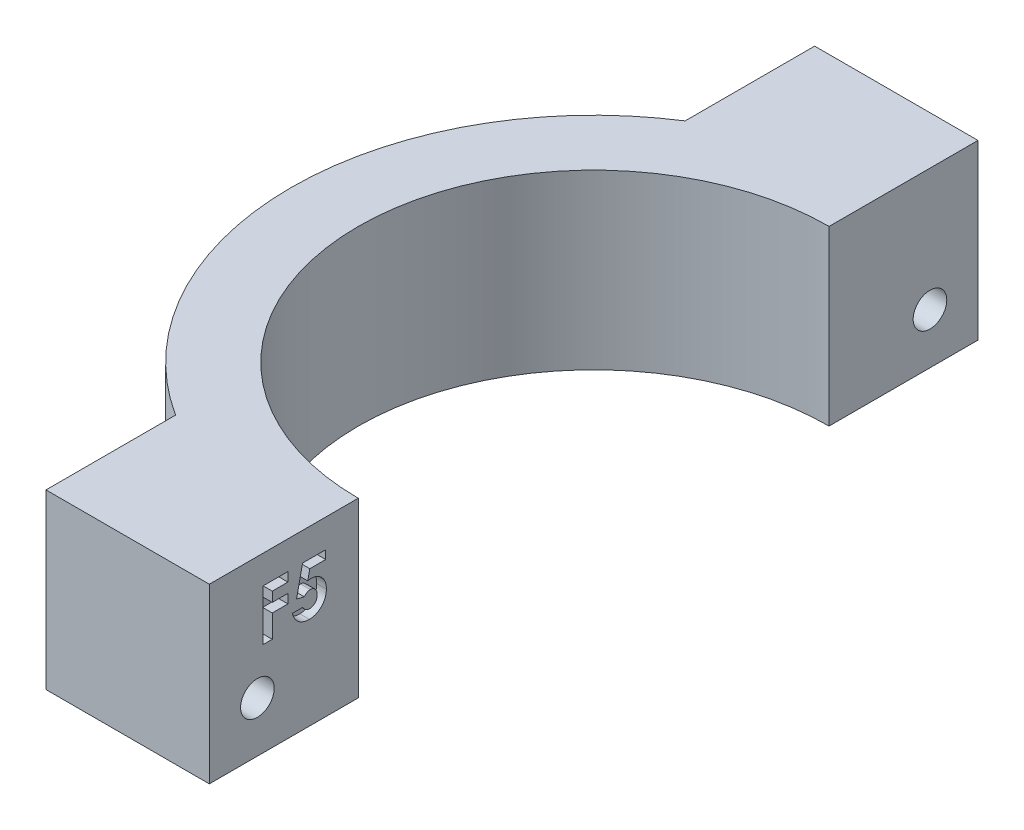
from build123d import *

# Parameters (mm, degrees)
BOSS_EXTRUDE1_DEPTH = 18
SKETCH2_R           = 1.75
CUT_EXTRUDE1_DEPTH  = 32.5
CUT_EXTRUDE2_DEPTH  = 1
CUT_EXTRUDE3_DEPTH  = 5


with BuildPart() as part:
    # Sketch1 → Boss-Extrude1 (new body)
    with BuildSketch(Plane(origin=(0, 0, 0), x_dir=(1, 0, 0), z_dir=(0, 1, 0))):
        with BuildLine():
            Line((-12.998275301, 32.528571429), (-29.998275301, 32.528571429))
            Line((-29.998275301, 32.528571429), (-29.998275301, 19.047432641))
            ThreePointArc((-29.998275301, 19.047432641), (-21.855641496, 22.757647896), (-12.998275301, 24.028571429))
            Line((-12.998275301, 24.028571429), (-12.998275301, 32.528571429))
        make_face()
        with BuildLine():
            ThreePointArc((-12.998275301, 24.028571429), (-21.855641496, 22.757647896), (-29.998275301, 19.047432641))
            ThreePointArc((-29.998275301, 19.047432641), (-44.498275301, -7.471428571), (-29.998275301, -33.990289784))
            ThreePointArc((-29.998275301, -33.990289784), (-21.855641496, -37.700505039), (-12.998275301, -38.971428571))
            Line((-12.998275301, -38.971428571), (-12.998275301, -31.971428571))
            ThreePointArc((-12.998275301, -31.971428571), (-37.498275301, -7.471428571), (-12.998275301, 17.028571429))
            Line((-12.998275301, 17.028571429), (-12.998275301, 24.028571429))
        make_face()
        with BuildLine():
            Line((-29.998275301, -33.990289784), (-29.998275301, -47.471428571))
            Line((-29.998275301, -47.471428571), (-12.998275301, -47.471428571))
            Line((-12.998275301, -47.471428571), (-12.998275301, -38.971428571))
            ThreePointArc((-12.998275301, -38.971428571), (-21.855641496, -37.700505039), (-29.998275301, -33.990289784))
        make_face()
    extrude(amount=BOSS_EXTRUDE1_DEPTH)

    # Sketch2 → Cut-Extrude1 (cut, through all)
    with BuildSketch(Plane(origin=(-12.998275301, 0, 0), x_dir=(0, 0, -1), z_dir=(1, 0, 0))):
        with Locations((-42.471428571, 5.25)):
            Circle(SKETCH2_R)
        with Locations((27.528571429, 5.25)):
            Circle(SKETCH2_R)
    extrude(amount=-CUT_EXTRUDE1_DEPTH, mode=Mode.SUBTRACT)

    # Sketch3 → Cut-Extrude2 (cut)
    with BuildSketch(Plane(origin=(-12.998275301, 0, 0), x_dir=(0, 0, -1), z_dir=(1, 0, 0))):
        Polygon((-41.872123333, 15.051635835), (-39.29413188, 15.051635835), (-39.29413188, 14.10184951), (-40.922337009, 14.10184951), (-40.922337009, 13.084221305), (-39.29413188, 13.084221305), (-39.29413188, 12.13443498), (-40.922337009, 12.13443498), (-40.922337009, 9.759969168), (-41.872123333, 9.759969168), align=None)
        with BuildLine():
            Line((-37.768749602, 15.051635835), (-35.359302821, 15.051635835))
            Line((-35.359302821, 15.051635835), (-35.359302821, 14.16969139))
            Line((-35.359302821, 14.16969139), (-37.016128742, 14.16969139))
            Line((-37.016128742, 14.16969139), (-37.222834471, 13.169023655))
            add(Edge.make_bspline(
                [(-37.222834471, 13.169023655), (-37.194667857, 13.176868413), (-37.139117506, 13.192339887), (-37.055430833, 13.207855818), (-36.974326785, 13.217912751), (-36.921106803, 13.219254212), (-36.895285393, 13.219905065)],
                knots=[0, 0, 0, 0, 8.7675e-05, 0.000172914, 0.000255092, 0.000332539, 0.000332539, 0.000332539, 0.000332539], degree=3))
            add(Edge.make_bspline(
                [(-36.895285393, 13.219905065), (-36.839017834, 13.218615727), (-36.728102081, 13.216074157), (-36.56584641, 13.191946365), (-36.410477019, 13.153945825), (-36.262469357, 13.099749215), (-36.121968006, 13.029210927), (-35.988802653, 12.943879371), (-35.862809858, 12.843604675), (-35.746227784, 12.728324059), (-35.639107304, 12.601743331), (-35.545972157, 12.464832881), (-35.466428929, 12.319544917), (-35.403162996, 12.164976334), (-35.353228128, 12.002097925), (-35.317144077, 11.830805314), (-35.295805775, 11.650895492), (-35.292928436, 11.528155884), (-35.29146094, 11.465556441)],
                knots=[0, 0, 0, 0, 0.000168708, 0.00033256, 0.000490931, 0.00064788, 0.00080432, 0.000961637, 0.001121557, 0.001286466, 0.001452728, 0.001618259, 0.001782383, 0.001948726, 0.00211839, 0.002292819, 0.002473214, 0.002660986, 0.002660986, 0.002660986, 0.002660986], degree=3))
            add(Edge.make_bspline(
                [(-35.29146094, 11.465556441), (-35.293254243, 11.402246349), (-35.296792955, 11.277317032), (-35.319879804, 11.093626745), (-35.360628507, 10.917692919), (-35.416600928, 10.749044582), (-35.490341009, 10.588921261), (-35.579023549, 10.435664197), (-35.684147931, 10.290410967), (-35.804682523, 10.154650595), (-35.935719436, 10.030563008), (-36.075242816, 9.921402921), (-36.22227247, 9.829545591), (-36.376811944, 9.75530934), (-36.537974597, 9.696574939), (-36.705809344, 9.653819098), (-36.881131839, 9.629301), (-37.000153034, 9.625975643), (-37.060649976, 9.624285407)],
                knots=[0, 0, 0, 0, 0.000189935, 0.000374797, 0.00055428, 0.000730936, 0.00090692, 0.001082188, 0.001261361, 0.001443849, 0.001626066, 0.00180206, 0.001974425, 0.002145103, 0.002315455, 0.002488223, 0.002663769, 0.002845232, 0.002845232, 0.002845232, 0.002845232], degree=3))
            add(Edge.make_bspline(
                [(-37.060649976, 9.624285407), (-37.11475059, 9.625668125), (-37.221448324, 9.628395135), (-37.378609401, 9.645156773), (-37.530130131, 9.674791505), (-37.675206106, 9.717680636), (-37.815363767, 9.770467365), (-37.94898285, 9.836487145), (-38.076797617, 9.914482872), (-38.198445122, 10.00303112), (-38.311948765, 10.102777287), (-38.415542863, 10.211966653), (-38.509854588, 10.329222939), (-38.592865818, 10.455992731), (-38.664316336, 10.592088734), (-38.727680113, 10.735907025), (-38.779543999, 10.888949526), (-38.805863427, 10.99504709), (-38.819238718, 11.048964895)],
                knots=[0, 0, 0, 0, 0.000162309, 0.000320108, 0.00047353, 0.000624818, 0.000773452, 0.00092231, 0.001071202, 0.001222162, 0.001373137, 0.001523844, 0.001673169, 0.001823995, 0.001977637, 0.002133811, 0.002295051, 0.002461661, 0.002461661, 0.002461661, 0.002461661], degree=3))
            Line((-38.819238718, 11.048964895), (-37.733768633, 11.048964895))
            add(Edge.make_bspline(
                [(-37.733768633, 11.048964895), (-37.713926213, 11.011602052), (-37.675364736, 10.938991631), (-37.60201228, 10.842590387), (-37.519898863, 10.760383548), (-37.429765192, 10.691567935), (-37.331027257, 10.640012448), (-37.227708443, 10.600915152), (-37.118510798, 10.578322273), (-37.044142381, 10.575497939), (-37.006588478, 10.574071732)],
                knots=[0, 0, 0, 0, 0.000126748, 0.00024632, 0.000361751, 0.000474538, 0.000585031, 0.000694707, 0.000805098, 0.000917705, 0.000917705, 0.000917705, 0.000917705], degree=3))
            add(Edge.make_bspline(
                [(-37.006588478, 10.574071732), (-36.980413911, 10.575056541), (-36.92891501, 10.576994168), (-36.853039524, 10.587244701), (-36.780613038, 10.60665898), (-36.71109708, 10.633543242), (-36.644304912, 10.667070955), (-36.581194023, 10.709397506), (-36.520666397, 10.758116937), (-36.46364351, 10.814022648), (-36.411997211, 10.876344513), (-36.366709056, 10.943313604), (-36.3262152, 11.013441856), (-36.296220781, 11.089507223), (-36.271657889, 11.169238367), (-36.253568781, 11.253236725), (-36.2427585, 11.341600399), (-36.241757757, 11.401923802), (-36.241247265, 11.43269553)],
                knots=[0, 0, 0, 0, 7.8557e-05, 0.000154562, 0.000229126, 0.000302949, 0.000377852, 0.000452822, 0.000530465, 0.000610671, 0.000691969, 0.000772824, 0.000853029, 0.000934327, 0.001017484, 0.001103143, 0.001191762, 0.001284039, 0.001284039, 0.001284039, 0.001284039], degree=3))
            add(Edge.make_bspline(
                [(-36.241247265, 11.43269553), (-36.24183975, 11.462752977), (-36.242993035, 11.521260526), (-36.252533243, 11.607170565), (-36.269600491, 11.688683645), (-36.292854763, 11.766424094), (-36.322623008, 11.839919836), (-36.359001793, 11.909608351), (-36.402146532, 11.975137391), (-36.452288859, 12.035172848), (-36.505760122, 12.090239076), (-36.56320544, 12.138399561), (-36.624107261, 12.178369419), (-36.686573137, 12.213264269), (-36.753096479, 12.238659979), (-36.822181447, 12.256149068), (-36.893755387, 12.268981858), (-36.942574418, 12.269735832), (-36.967367391, 12.270118741)],
                knots=[0, 0, 0, 0, 9.0159e-05, 0.000175496, 0.000258862, 0.000339682, 0.000418616, 0.000496375, 0.000575167, 0.000653481, 0.000730688, 0.0008052, 0.000877818, 0.000948966, 0.00101944, 0.00109066, 0.001162633, 0.001236903, 0.001236903, 0.001236903, 0.001236903], degree=3))
            add(Edge.make_bspline(
                [(-36.967367391, 12.270118741), (-36.994298321, 12.269096861), (-37.048273682, 12.267048796), (-37.12846756, 12.250384238), (-37.207694523, 12.22341473), (-37.286395154, 12.186206021), (-37.363788212, 12.13751156), (-37.44191614, 12.080398541), (-37.518163827, 12.010717161), (-37.566644228, 11.95881831), (-37.591724696, 11.931969368)],
                knots=[0, 0, 0, 0, 8.0736e-05, 0.000161813, 0.000244611, 0.000331384, 0.000422288, 0.00051854, 0.000621363, 0.000731571, 0.000731571, 0.000731571, 0.000731571], degree=3))
            Line((-37.591724696, 11.931969368), (-38.390986848, 12.115354451))
            Line((-38.390986848, 12.115354451), (-37.768749602, 15.051635835))
        make_face()
    extrude(amount=-CUT_EXTRUDE2_DEPTH, mode=Mode.SUBTRACT)

    # Sketch4 → Cut-Extrude3 (cut)
    with BuildSketch(Plane.ZY.offset(29.998275301)):
        Polygon((-25.65109293, 2.689061145), (-24.371994073, 5.595474648), (-26.249472572, 8.156413503), (-29.406049928, 7.810938855), (-30.685148784, 4.904525352), (-28.807670285, 2.343586497), align=None)
        Polygon((44.048403814, 2.493828304), (45.646830899, 5.237614774), (44.069855656, 7.993786469), (40.894453329, 8.006171696), (39.296026244, 5.262385226), (40.873001487, 2.506213531), align=None)
    extrude(amount=-CUT_EXTRUDE3_DEPTH, mode=Mode.SUBTRACT)


solid = part.part
